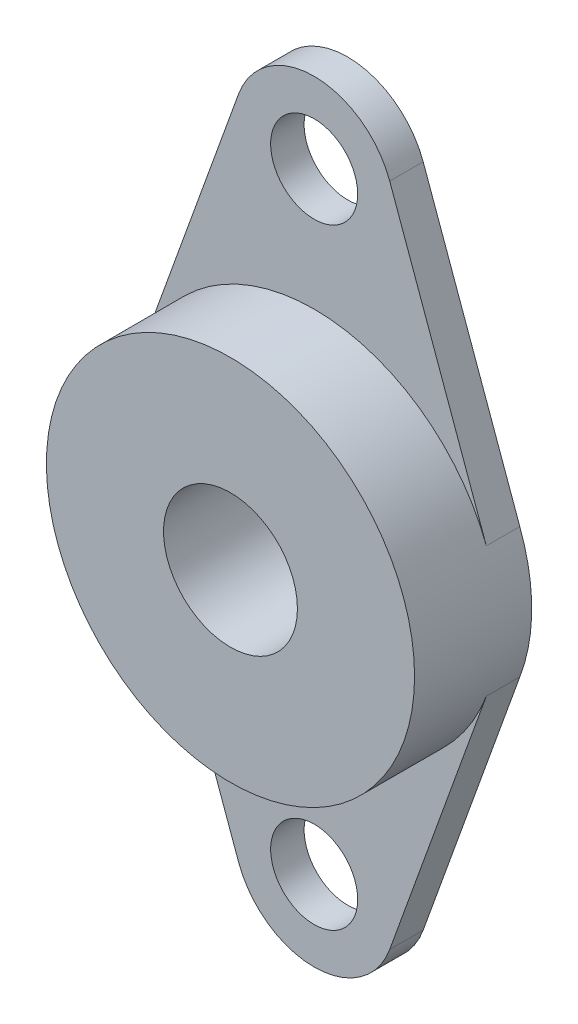
from build123d import *

# Parameters (mm, degrees)
CROQUIS1_R              = 4
CROQUIS1_R_2            = 2.6
SALIENTE_EXTRUIR1_DEPTH = 7
CROQUIS2_R              = 2.6
CORTAR_EXTRUIR1_DEPTH   = 5


with BuildPart() as part:
    # Croquis1 → Saliente-Extruir1 (new body)
    with BuildSketch(Plane.XY):
        with BuildLine():
            Line((10.288824315, -3.891027397), (4.514634908, -19.880359362))
            ThreePointArc((4.514634908, -19.880359362), (0, -23.05), (-4.514634908, -19.880359362))
            Line((-4.514634908, -19.880359362), (-10.288824315, -3.891027397))
            ThreePointArc((-10.288824315, -3.891027397), (-11, 0), (-10.288824315, 3.891027397))
            Line((-10.288824315, 3.891027397), (-4.514634908, 19.880359362))
            ThreePointArc((-4.514634908, 19.880359362), (0, 23.05), (4.514634908, 19.880359362))
            Line((4.514634908, 19.880359362), (10.288824315, 3.891027397))
            ThreePointArc((10.288824315, 3.891027397), (11, 0), (10.288824315, -3.891027397))
        make_face()
        Circle(CROQUIS1_R, mode=Mode.SUBTRACT)
        with Locations((0, 18.25)):
            Circle(CROQUIS1_R_2, mode=Mode.SUBTRACT)
        with Locations((0, -18.25)):
            Circle(CROQUIS1_R_2, mode=Mode.SUBTRACT)
    extrude(amount=SALIENTE_EXTRUIR1_DEPTH)

    # Croquis2 → Cortar-Extruir1 (cut)
    with BuildSketch(Plane.XY.offset(7)):
        with BuildLine():
            Line((-4.514634908, 19.880359362), (-10.288824315, 3.891027397))
            ThreePointArc((-10.288824315, 3.891027397), (0, 11), (10.288824315, 3.891027397))
            Line((10.288824315, 3.891027397), (4.514634908, 19.880359362))
            ThreePointArc((4.514634908, 19.880359362), (0, 23.05), (-4.514634908, 19.880359362))
        make_face()
        with Locations((0, 18.25)):
            Circle(CROQUIS2_R, mode=Mode.SUBTRACT)
        with BuildLine():
            ThreePointArc((10.288824315, -3.891027397), (0, -11), (-10.288824315, -3.891027397))
            Line((-10.288824315, -3.891027397), (-4.514634908, -19.880359362))
            ThreePointArc((-4.514634908, -19.880359362), (0, -23.05), (4.514634908, -19.880359362))
            Line((4.514634908, -19.880359362), (10.288824315, -3.891027397))
        make_face()
        with Locations((0, -18.25)):
            Circle(CROQUIS2_R, mode=Mode.SUBTRACT)
    extrude(amount=-CORTAR_EXTRUIR1_DEPTH, mode=Mode.SUBTRACT)


solid = part.part
